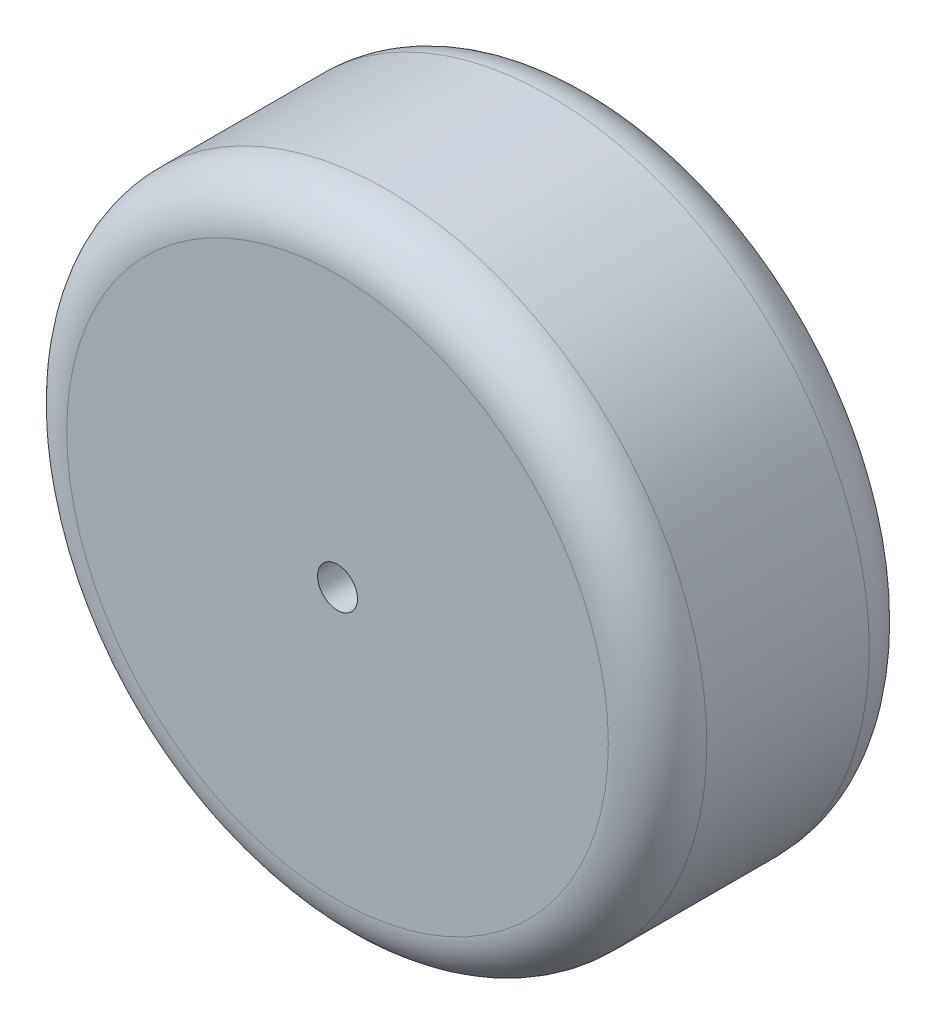
from build123d import *

# Parameters (mm, degrees)
ESBO_O1_R                = 32.5
RESSALTO_EXTRUS_O1_DEPTH = 26.5
ESBO_O2_R                = 22.5
CORTE_EXTRUS_O1_DEPTH    = 23.5
ESBO_O3_R                = 9
RESSALTO_EXTRUS_O2_DEPTH = 15
FILETE1_R                = 4
ESBO_O4_R                = 2.025
CORTE_EXTRUS_O2_DEPTH    = 27.5
FILLET1_R                = 5


with BuildPart() as part:
    # Esboço1 → Ressalto-extrusão1 (new body)
    with BuildSketch(Plane.XY):
        Circle(ESBO_O1_R)
    extrude(amount=RESSALTO_EXTRUS_O1_DEPTH)

    # Esboço2 → Corte-extrusão1 (cut)
    with BuildSketch(Plane(origin=(0, 0, 0), x_dir=(-1, 0, 0), z_dir=(0, 0, -1))):
        Circle(ESBO_O2_R)
    extrude(amount=-CORTE_EXTRUS_O1_DEPTH, mode=Mode.SUBTRACT)

    # Esboço3 → Ressalto-extrusão2 (add)
    with BuildSketch(Plane(origin=(0, 0, 23.5), x_dir=(-1, 0, 0), z_dir=(0, 0, -1))):
        Circle(ESBO_O3_R)
        Polygon((6, -3.464101615), (6, 3.464101615), (0, 6.92820323), (-6, 3.464101615), (-6, -3.464101615), (0, -6.92820323), align=None, mode=Mode.SUBTRACT)
    extrude(amount=RESSALTO_EXTRUS_O2_DEPTH)

    # Filete1
    filete1_edges = [part.edges().sort_by_distance(p)[0] for p in [
        (9, 0, 23.5),
    ]]
    fillet(filete1_edges, radius=FILETE1_R)

    # Esboço4 → Corte-extrusão2 (cut, through all)
    with BuildSketch(Plane.XY.offset(26.5)):
        Circle(ESBO_O4_R)
    extrude(amount=-CORTE_EXTRUS_O2_DEPTH, mode=Mode.SUBTRACT)

    # Fillet1
    fillet1_edges = [part.edges().sort_by_distance(p)[0] for p in [
        (-32.5, 0, 0),
        (-32.5, 0, 26.5),
    ]]
    fillet(fillet1_edges, radius=FILLET1_R)


solid = part.part
